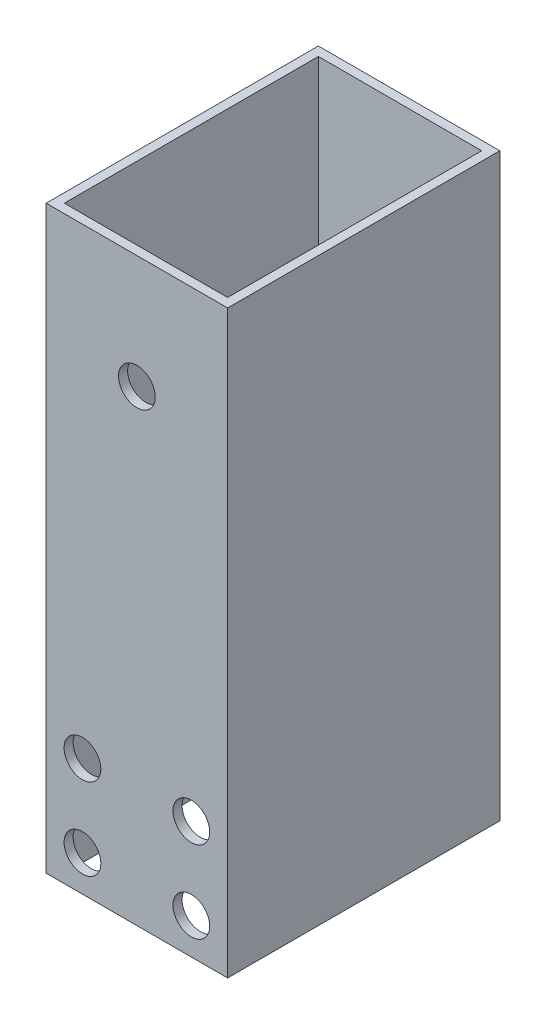
from build123d import *

# Parameters (mm, degrees)
SKETCH_2_W               = 20
SKETCH_2_H               = 30
EXTRUDE_1_DEPTH          = 61.5
SKETCH_3_W               = 18
SKETCH_3_H               = 28
CUT_EXTRUDE_1_DEPTH      = 62.5
CUT_EXTRUDE_1_DEPTH_BACK = 62.5
SKETCH_4_W               = 30
SKETCH_4_H               = 45.05
CUT_EXTRUDE_2_DEPTH      = 21
SKETCH_5_R               = 2.025
CUT_EXTRUDE_3_DEPTH      = 31
SKETCH_6_W               = 20
SKETCH_6_H               = 14
CUT_EXTRUDE_4_DEPTH      = 1
CUT_EXTRUDE_4_DEPTH_BACK = 31
SKETCH_7_R               = 2.025
CUT_EXTRUDE_5_DEPTH      = 1
CUT_EXTRUDE_5_DEPTH_BACK = 31
SKETCH_8_R               = 2.025
CUT_EXTRUDE_6_DEPTH      = 31


with BuildPart() as part:
    # 草图2 → 凸台-拉伸1 (new body, symmetric)
    with BuildSketch(Plane(origin=(0, 0, 0), x_dir=(1, 0, 0), z_dir=(0, 1, 0))):
        Rectangle(SKETCH_2_W, SKETCH_2_H)
    extrude(amount=EXTRUDE_1_DEPTH, both=True)

    # 草图3 → 切除-拉伸1 (cut, two sides)
    with BuildSketch(Plane(origin=(0, 0, 0), x_dir=(1, 0, 0), z_dir=(0, 1, 0))) as cut_extrude_1_sk:
        Rectangle(SKETCH_3_W, SKETCH_3_H)
    extrude(amount=CUT_EXTRUDE_1_DEPTH, mode=Mode.SUBTRACT)
    extrude(cut_extrude_1_sk.sketch, amount=-CUT_EXTRUDE_1_DEPTH_BACK, mode=Mode.SUBTRACT)

    # 草图4 → 切除-拉伸2 (cut, through all)
    with BuildSketch(Plane.ZY.offset(10)):
        with Locations((0, 38.975)):
            Rectangle(SKETCH_4_W, SKETCH_4_H)
    extrude(amount=-CUT_EXTRUDE_2_DEPTH, mode=Mode.SUBTRACT)

    # 草图5 → 切除-拉伸3 (cut, through all)
    with BuildSketch(Plane.XY.offset(15)):
        with Locations((-6, -48.55)):
            Circle(SKETCH_5_R)
        with Locations((6, -48.55)):
            Circle(SKETCH_5_R)
    extrude(amount=-CUT_EXTRUDE_3_DEPTH, mode=Mode.SUBTRACT)

    # 草图6 → 切除-拉伸4 (cut, two sides)
    with BuildSketch(Plane.XY.offset(15)) as cut_extrude_4_sk:
        with Locations((0, 9.45)):
            Rectangle(SKETCH_6_W, SKETCH_6_H)
    extrude(amount=CUT_EXTRUDE_4_DEPTH, mode=Mode.SUBTRACT)
    extrude(cut_extrude_4_sk.sketch, amount=-CUT_EXTRUDE_4_DEPTH_BACK, mode=Mode.SUBTRACT)

    # 草图7 → 切除-拉伸5 (cut, two sides)
    with BuildSketch(Plane.XY.offset(15)) as cut_extrude_5_sk:
        with Locations((-6, -57.55)):
            Circle(SKETCH_7_R)
        with Locations((6, -57.55)):
            Circle(SKETCH_7_R)
    extrude(amount=CUT_EXTRUDE_5_DEPTH, mode=Mode.SUBTRACT)
    extrude(cut_extrude_5_sk.sketch, amount=-CUT_EXTRUDE_5_DEPTH_BACK, mode=Mode.SUBTRACT)

    # 草图8 → 切除-拉伸6 (cut, through all)
    with BuildSketch(Plane.XY.offset(15)):
        with Locations((0, -10.05)):
            Circle(SKETCH_8_R)
    extrude(amount=-CUT_EXTRUDE_6_DEPTH, mode=Mode.SUBTRACT)


solid = part.part
